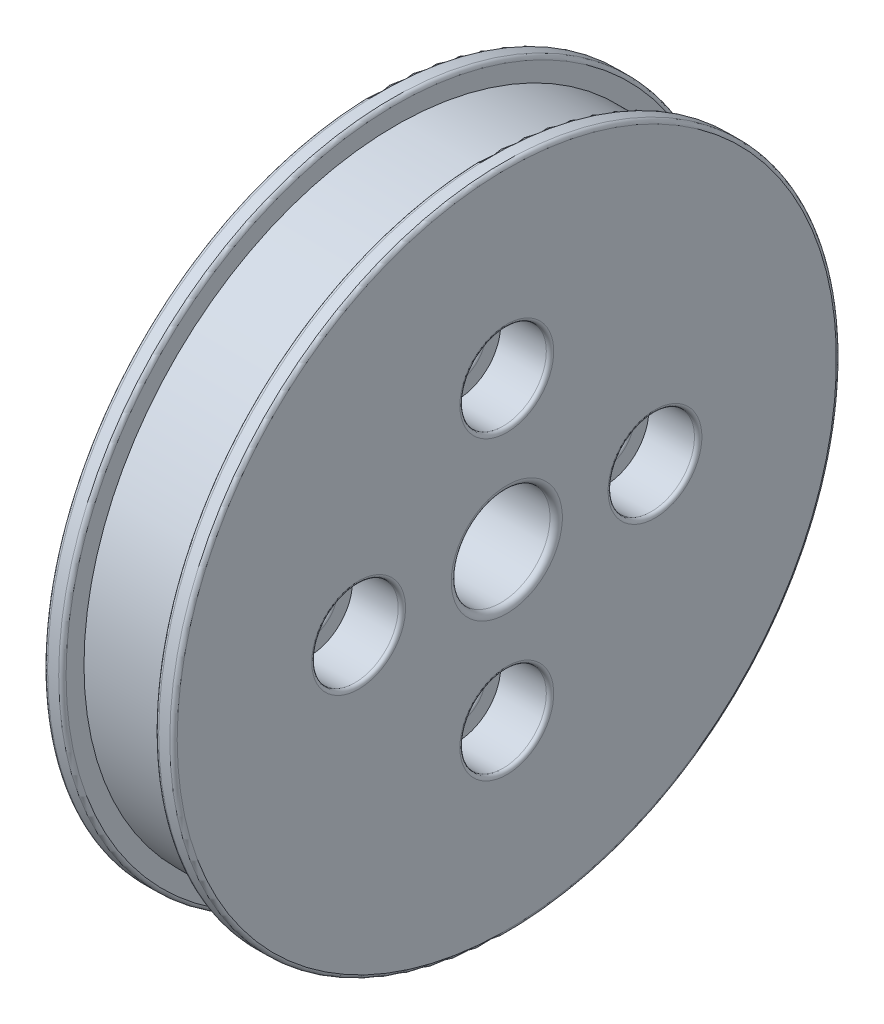
from build123d import *

# Parameters (mm, degrees)
FILLET1_R          = 0.3
SKETCH2_R          = 2
CUT_EXTRUDE1_DEPTH = 40.601136416
SKETCH2_3_R        = 3.5
CUT_EXTRUDE2_DEPTH = 4
FILLET2_R          = 0.3
FILLET3_R          = 0.5


with BuildPart() as part:
    # Sketch1 → Revolve1 (revolve)
    with BuildSketch(Plane(origin=(0, 0, 0), x_dir=(1, 0, 0), z_dir=(0, 1, 0))):
        Polygon((0, 4), (0, 27), (1.5, 27), (1.5, 25.25), (9, 25.25), (9, 27), (10.5, 27), (10.5, 17.5), (10.5, 4), align=None)
    revolve(axis=Axis((0, 0, 0), (1, 0, 0)))

    # Fillet1
    fillet1_edges = [part.edges().sort_by_distance(p)[0] for p in [
        (0, 0, 4),
        (0, 0, 27),
        (1.5, 0, 27),
        (9, 0, 27),
        (10.5, 0, 27),
    ]]
    fillet(fillet1_edges, radius=FILLET1_R)

    # Sketch2 → Cut-Extrude1 (cut, through all)
    with BuildSketch(Plane(origin=(10.5, 0, 0), x_dir=(0, 0, -1), z_dir=(1, 0, 0))):
        with Locations((-12, 0)):
            Circle(SKETCH2_R)
        with Locations((0, 12)):
            Circle(SKETCH2_R)
        with Locations((12, 0)):
            Circle(SKETCH2_R)
        with Locations((0, -12)):
            Circle(SKETCH2_R)
    extrude(amount=-CUT_EXTRUDE1_DEPTH, mode=Mode.SUBTRACT)

    # Sketch2_3 → Cut-Extrude2 (cut)
    with BuildSketch(Plane(origin=(10.5, 0, 0), x_dir=(0, 0, -1), z_dir=(1, 0, 0))):
        with Locations((-12, 0)):
            Circle(SKETCH2_3_R)
        with Locations((0, 12)):
            Circle(SKETCH2_3_R)
        with Locations((12, 0)):
            Circle(SKETCH2_3_R)
        with Locations((0, -12)):
            Circle(SKETCH2_3_R)
    extrude(amount=-CUT_EXTRUDE2_DEPTH, mode=Mode.SUBTRACT)

    # Fillet2
    fillet2_edges = [part.edges().sort_by_distance(p)[0] for p in [
        (6.5, -12, 2),
        (10.5, -12, 3.5),
        (6.5, 0, -10),
        (10.5, 0, -8.5),
        (6.5, 0, 14),
        (10.5, 0, 15.5),
        (6.5, 12, 2),
        (10.5, 12, 3.5),
        (0, 12, 2),
        (0, 0, -10),
        (0, 0, 14),
        (0, -12, 2),
    ]]
    fillet(fillet2_edges, radius=FILLET2_R)

    # Fillet3
    fillet3_edges = [part.edges().sort_by_distance(p)[0] for p in [
        (10.5, 0, 4),
    ]]
    fillet(fillet3_edges, radius=FILLET3_R)


solid = part.part
